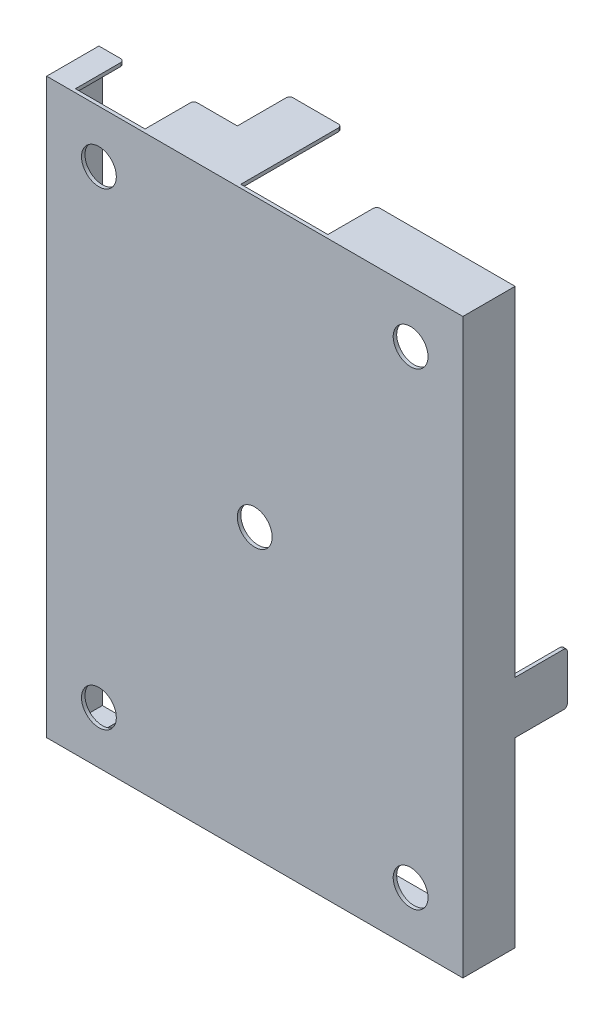
from build123d import *

# Parameters (mm, degrees)
SKETCH_1_W          = 23.9
SKETCH_1_H          = 32.9
EXTRUDE_1_DEPTH     = 3
SHELL_1_T           = -0.2
SKETCH_3_2_W        = 9
SKETCH_3_2_H        = 0.2
SKETCH_3_2_W_2      = 2
SKETCH_3_2_W_3      = 5
SKETCH_3_2_W_4      = 4
CUT_EXTRUDE_3_DEPTH = 2.8
SKETCH_3_W          = 3
SKETCH_3_H          = 0.2
SKETCH_3_W_2        = 0.2
SKETCH_3_H_2        = 3
EXTRUDE_2_DEPTH     = 3
FILLET_1_R          = 0.2
SKETCH_5_R          = 1
CUT_EXTRUDE_5_DEPTH = 7


with BuildPart() as part:
    # Sketch 1 → Extrude 1 (new body)
    with BuildSketch(Plane.XY):
        with Locations((11.8, 16.3)):
            Rectangle(SKETCH_1_W, SKETCH_1_H)
    extrude(amount=EXTRUDE_1_DEPTH)

    # Shell 1
    shell_1_openings = [part.faces().sort_by_distance(p)[0] for p in [
        (11.8, 16.3, 0),
    ]]
    offset(amount=SHELL_1_T, openings=shell_1_openings, kind=Kind.INTERSECTION)

    # Sketch 3_2 → Cut-Extrude 3 (cut)
    with BuildSketch(Plane(origin=(0, 0, 0), x_dir=(-1, 0, 0), z_dir=(0, 0, -1))):
        with Locations((-5.8, -0.05)):
            Rectangle(SKETCH_3_2_W, SKETCH_3_2_H)
        with Locations((-21.3, -0.05)):
            Rectangle(SKETCH_3_2_W_2, SKETCH_3_2_H)
        with Locations((-13.3, 32.65)):
            Rectangle(SKETCH_3_2_W_3, SKETCH_3_2_H)
        with Locations((-3.3, 32.65)):
            Rectangle(SKETCH_3_2_W_4, SKETCH_3_2_H)
    extrude(amount=-CUT_EXTRUDE_3_DEPTH, mode=Mode.SUBTRACT)

    # Sketch 3 → Extrude 2 (add)
    with BuildSketch(Plane(origin=(0, 0, 0), x_dir=(-1, 0, 0), z_dir=(0, 0, -1))):
        with Locations((-9.3, 32.65)):
            Rectangle(SKETCH_3_W, SKETCH_3_H)
        with Locations((0.05, 11.8)):
            Rectangle(SKETCH_3_W_2, SKETCH_3_H_2)
        with Locations((-23.65, 11.8)):
            Rectangle(SKETCH_3_W_2, SKETCH_3_H_2)
    extrude(amount=EXTRUDE_2_DEPTH)

    # Fillet 1
    fillet_1_edges = [part.edges().sort_by_distance(p)[0] for p in [
        (-0.05, 13.3, -3),
        (-0.05, 10.3, -3),
        (23.65, 13.3, -3),
        (23.65, 10.3, -3),
        (1.3, -0.05, 0),
        (10.3, -0.05, 0),
        (20.3, -0.05, 0),
        (22.3, -0.05, 0),
        (15.8, 32.65, 0),
        (1.3, 32.65, 0),
        (5.3, 32.65, 0),
        (7.8, 32.65, -3),
        (10.8, 32.65, -3),
    ]]
    fillet(fillet_1_edges, radius=FILLET_1_R)

    # Sketch 5 → Cut-Extrude 5 (cut, through all)
    with BuildSketch(Plane.XY.offset(3)):
        with Locations((11.8, 16.3)):
            Circle(SKETCH_5_R)
        with Locations((2.85, 29.75)):
            Circle(SKETCH_5_R)
        with Locations((2.85, 2.85)):
            Circle(SKETCH_5_R)
        with Locations((20.75, 2.85)):
            Circle(SKETCH_5_R)
        with Locations((20.75, 29.75)):
            Circle(SKETCH_5_R)
    extrude(amount=-CUT_EXTRUDE_5_DEPTH, mode=Mode.SUBTRACT)


solid = part.part
